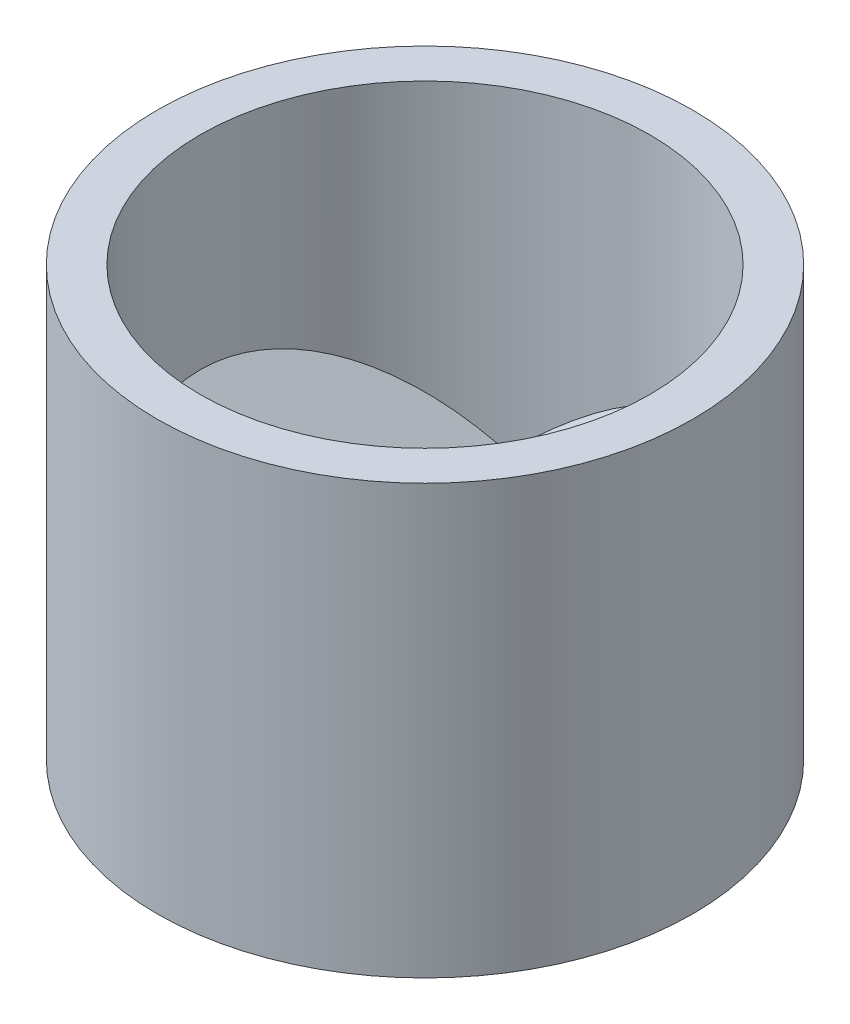
from build123d import *

# Parameters (mm, degrees)
SKETCH1_R           = 12.5
SKETCH1_R_2         = 10.5
BOSS_EXTRUDE1_DEPTH = 20
BOSS_EXTRUDE2_DEPTH = 1
CIRPATTERN1_COUNT   = 3


with BuildPart() as part:
    # Sketch1 → Boss-Extrude1 (new body)
    with BuildSketch(Plane(origin=(0, 0, 0), x_dir=(1, 0, 0), z_dir=(0, 1, 0))):
        Circle(SKETCH1_R)
        Circle(SKETCH1_R_2, mode=Mode.SUBTRACT)
    extrude(amount=BOSS_EXTRUDE1_DEPTH)

    # Sketch4 → Boss-Extrude2 (add)
    with BuildSketch(Plane(origin=(0, 0, 0), x_dir=(0, 0, 1), z_dir=(0.707106781, 0.707106781, 0))):
        with BuildLine():
            Line((-9.363412571, -8.137222405), (0, -1.322062821))
            Line((0, -1.322062821), (9.559751039, -8.008067831))
            ThreePointArc((9.559751039, -8.008067831), (0.151357729, -15.865590891), (-9.363412571, -8.137222405))
        make_face()
    boss_extrude2 = extrude(amount=-BOSS_EXTRUDE2_DEPTH)

    # CirPattern1: Boss-Extrude2 ×3 about axis
    cirpattern1_axis = Axis((0, 0, 0), (0, 1, 0))
    for i in range(1, CIRPATTERN1_COUNT):
        add(boss_extrude2.rotate(cirpattern1_axis, i * 360 / CIRPATTERN1_COUNT))


solid = part.part
